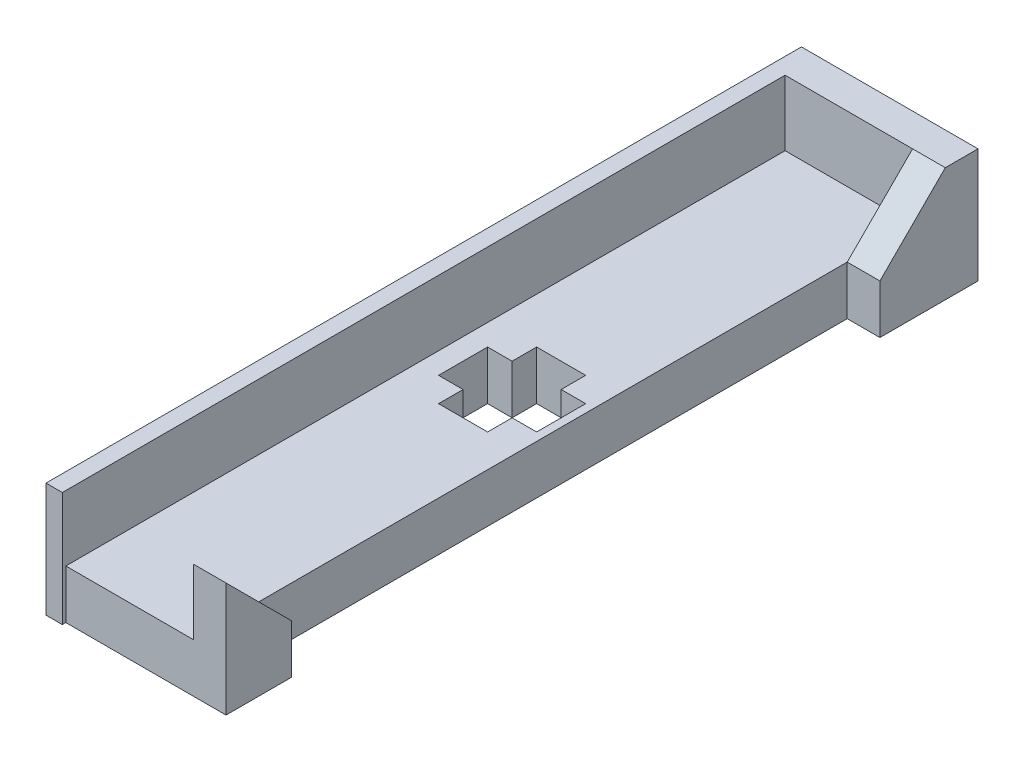
from build123d import *

# Parameters (mm, degrees)
SKETCH_1_W          = 7.8
SKETCH_1_H          = 44
EXTRUDE_1_DEPTH     = 3
SKETCH_2_W          = 7.8
SKETCH_2_H          = 7
EXTRUDE_2_DEPTH     = 2
EXTRUDE_3_DEPTH     = 2
EXTRUDE_4_DEPTH     = 2
SKETCH_6_W          = 46.213242819
SKETCH_6_H          = 7
EXTRUDE_5_DEPTH     = 1
SKETCH_7_W          = 3
SKETCH_7_H          = 6
CUT_EXTRUDE_1_DEPTH = 3
SKETCH_8_W          = 6
SKETCH_8_H          = 3
CUT_EXTRUDE_2_DEPTH = 3


with BuildPart() as part:
    # 草图1 → 凸台-拉伸1 (new body)
    with BuildSketch(Plane(origin=(0, 0, 0), x_dir=(1, 0, 0), z_dir=(0, 1, 0))):
        with Locations((-7.618235554, 22)):
            Rectangle(SKETCH_1_W, SKETCH_1_H)
    extrude(amount=EXTRUDE_1_DEPTH)

    # 草图2 → 凸台-拉伸2 (add)
    with BuildSketch(Plane(origin=(0, 0, -44), x_dir=(-1, 0, 0), z_dir=(0, 0, -1))):
        with Locations((7.618235554, 3.5)):
            Rectangle(SKETCH_2_W, SKETCH_2_H)
    extrude(amount=EXTRUDE_2_DEPTH)

    # 草图4 → 凸台-拉伸3 (add)
    with BuildSketch(Plane(origin=(-3.718235554, 0, 0), x_dir=(0, 0, -1), z_dir=(1, 0, 0))):
        Polygon((46, 7), (44, 7), (40, 3), (40, 0), (46, 0), align=None)
    extrude(amount=EXTRUDE_3_DEPTH)

    # 草图5 → 凸台-拉伸4 (add)
    with BuildSketch(Plane(origin=(-3.718235554, 0, 0), x_dir=(0, 0, -1), z_dir=(1, 0, 0))):
        Polygon((0, 0), (0, 7), (4, 3), (4, 0), align=None)
    extrude(amount=EXTRUDE_4_DEPTH)

    # 草图6 → 凸台-拉伸5 (add)
    with BuildSketch(Plane.ZY.offset(11.518235554)):
        with Locations((-22.89337859, 3.5)):
            Rectangle(SKETCH_6_W, SKETCH_6_H)
    extrude(amount=EXTRUDE_5_DEPTH)

    # 草图7 → 切除-拉伸1 (cut)
    with BuildSketch(Plane.XZ):
        with Locations((-7.218235554, -23)):
            Rectangle(SKETCH_7_W, SKETCH_7_H)
    extrude(amount=-CUT_EXTRUDE_1_DEPTH, mode=Mode.SUBTRACT)

    # 草图8 → 切除-拉伸2 (cut)
    with BuildSketch(Plane.XZ):
        with Locations((-7.218235554, -23)):
            Rectangle(SKETCH_8_W, SKETCH_8_H)
    extrude(amount=-CUT_EXTRUDE_2_DEPTH, mode=Mode.SUBTRACT)


solid = part.part
